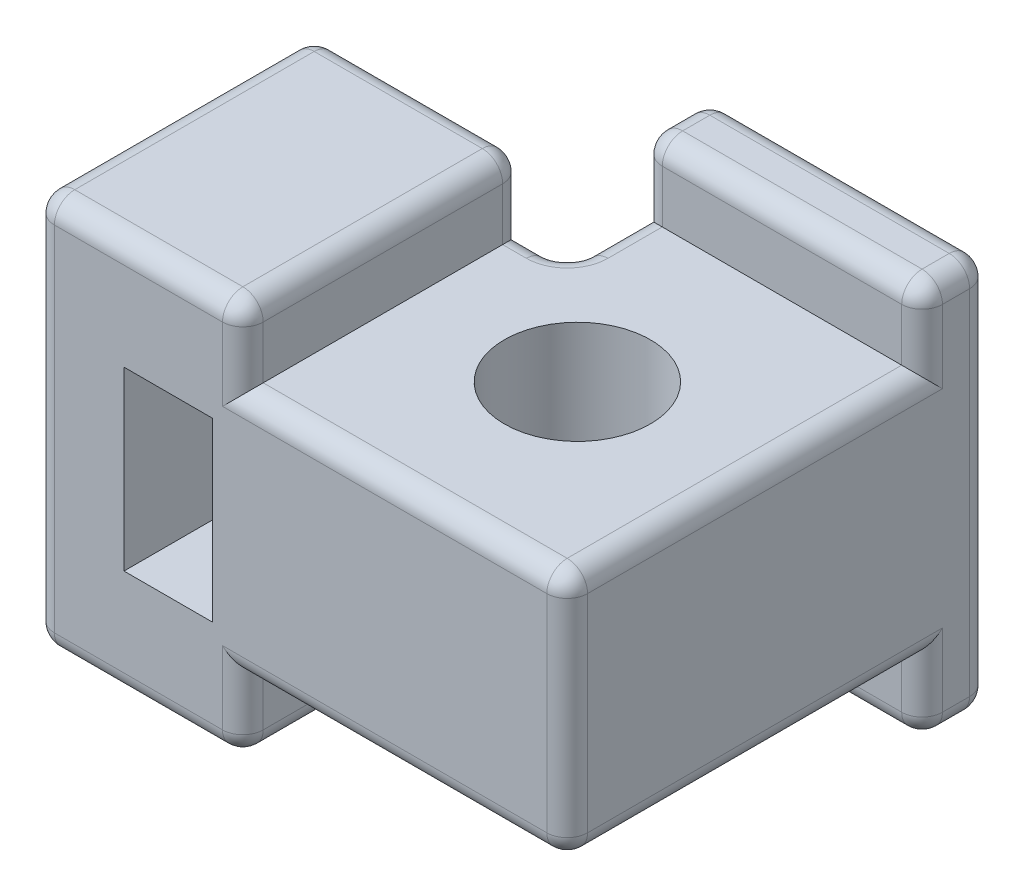
from build123d import *

# Parameters (mm, degrees)
SKETCH1_R           = 2.7305
BOSS_EXTRUDE1_DEPTH = 4.6355
SKETCH2_W           = 10.4775
SKETCH2_H           = 9.271
BOSS_EXTRUDE2_DEPTH = 2.54
SKETCH3_W           = 10.4775
SKETCH3_H           = 2.54
SKETCH3_W_2         = 7.8105
SKETCH3_H_2         = 10.4775
BOSS_EXTRUDE3_DEPTH = 7.366
SKETCH4_W           = 3.302
SKETCH4_H           = 6.604
CUT_EXTRUDE1_DEPTH  = 10.4775
FILLET1_R           = 0.762


with BuildPart() as part:
    # Sketch1 → Boss-Extrude1 (new body, symmetric)
    with BuildSketch(Plane(origin=(0, 0, 0), x_dir=(1, 0, 0), z_dir=(0, 1, 0))):
        Polygon((-11.1125, 3.81), (-4.191, 3.81), (-4.191, 9.144), (6.2865, 9.144), (6.2865, -6.6675), (-11.1125, -6.6675), align=None)
        Circle(SKETCH1_R, mode=Mode.SUBTRACT)
    extrude(amount=BOSS_EXTRUDE1_DEPTH, both=True)

    # Sketch2 → Boss-Extrude2 (add)
    with BuildSketch(Plane.ZY.offset(11.1125)):
        with Locations((1.42875, 0)):
            Rectangle(SKETCH2_W, SKETCH2_H)
    extrude(amount=BOSS_EXTRUDE2_DEPTH)

    # Sketch3 → Boss-Extrude3 (add, symmetric)
    with BuildSketch(Plane(origin=(0, 0, 0), x_dir=(1, 0, 0), z_dir=(0, 1, 0))):
        with Locations((1.04775, 7.874)):
            Rectangle(SKETCH3_W, SKETCH3_H)
        with Locations((-9.74725, -1.42875)):
            Rectangle(SKETCH3_W_2, SKETCH3_H_2)
    extrude(amount=BOSS_EXTRUDE3_DEPTH, both=True)

    # Sketch4 → Cut-Extrude1 (cut)
    with BuildSketch(Plane(origin=(0, 0, -3.81), x_dir=(-1, 0, 0), z_dir=(0, 0, -1))):
        with Locations((8.636, 0)):
            Rectangle(SKETCH4_W, SKETCH4_H)
    extrude(amount=-CUT_EXTRUDE1_DEPTH, mode=Mode.SUBTRACT)

    # Fillet1
    fillet1_edges = [part.edges().sort_by_distance(p)[0] for p in [
        (6.2865, 4.6355, 0.03175),
        (-4.191, 0, -3.81),
        (-4.191, 0, -9.144),
        (6.2865, 0, -9.144),
        (6.2865, 0, 6.6675),
        (-5.0165, 4.6355, -3.81),
        (-13.6525, 0, -3.81),
        (-13.6525, 0, 6.6675),
        (-4.191, -4.6355, -5.207),
        (-4.191, 4.6355, -5.207),
        (6.2865, 6.00075, -6.604),
        (-4.191, 6.00075, -6.604),
        (6.2865, -6.00075, -6.604),
        (6.2865, -7.366, -7.874),
        (1.04775, -7.366, -9.144),
        (-4.191, -7.366, -7.874),
        (-4.191, -6.00075, -6.604),
        (1.04775, -7.366, -6.604),
        (6.2865, 7.366, -7.874),
        (1.04775, 7.366, -9.144),
        (-4.191, 7.366, -7.874),
        (1.04775, 7.366, -6.604),
        (0.22225, -4.6355, 6.6675),
        (0.22225, 4.6355, 6.6675),
        (-5.842, 6.00075, 6.6675),
        (-5.842, 6.00075, -3.81),
        (-5.842, -6.00075, 6.6675),
        (-5.842, -7.366, 1.42875),
        (-5.842, -6.00075, -3.81),
        (-9.74725, -7.366, -3.81),
        (-13.6525, -7.366, 1.42875),
        (-9.74725, -7.366, 6.6675),
        (-5.0165, -4.6355, -3.81),
        (-5.842, 7.366, 1.42875),
        (-9.74725, 7.366, -3.81),
        (-13.6525, 7.366, 1.42875),
        (-9.74725, 7.366, 6.6675),
        (6.2865, -4.6355, 0.03175),
    ]]
    fillet(fillet1_edges, radius=FILLET1_R)


solid = part.part
